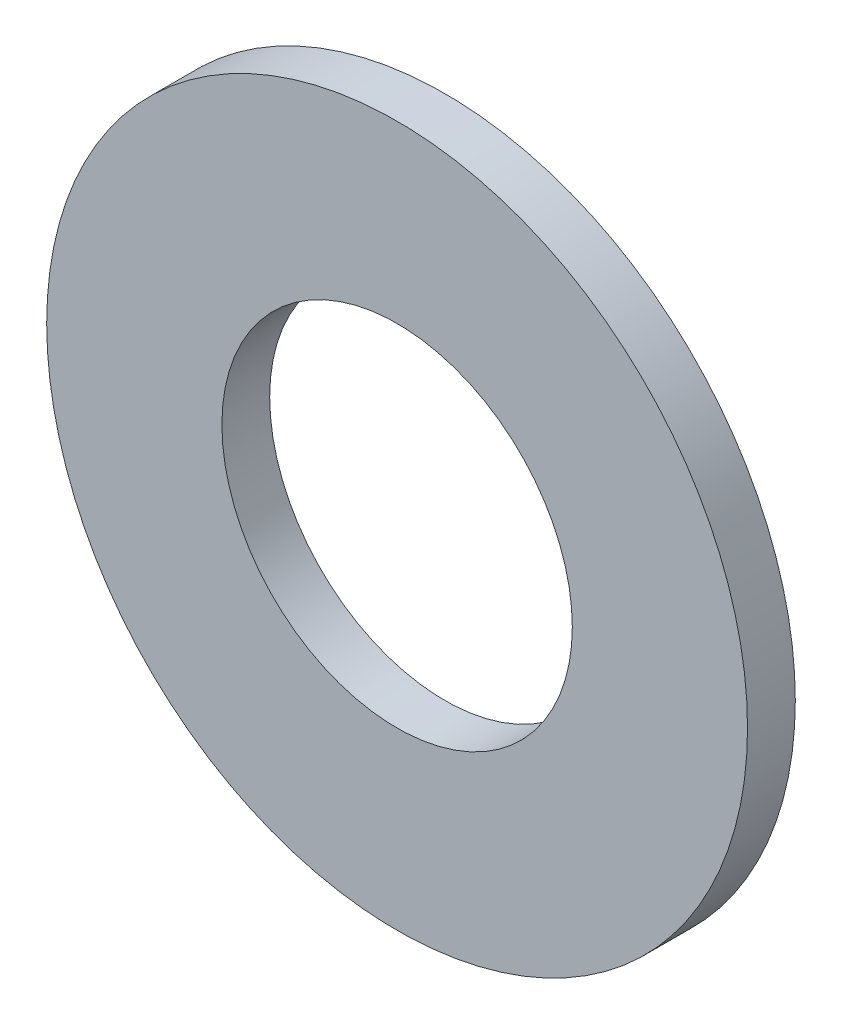
from build123d import *

# Parameters (mm, degrees)
SKETCH1_R           = 11
SKETCH1_R_2         = 5.5
BOSS_EXTRUDE1_DEPTH = 1.5


with BuildPart() as part:
    # Sketch1 → Boss-Extrude1 (new body)
    with BuildSketch(Plane.XY):
        Circle(SKETCH1_R)
        Circle(SKETCH1_R_2, mode=Mode.SUBTRACT)
    extrude(amount=BOSS_EXTRUDE1_DEPTH)


solid = part.part
